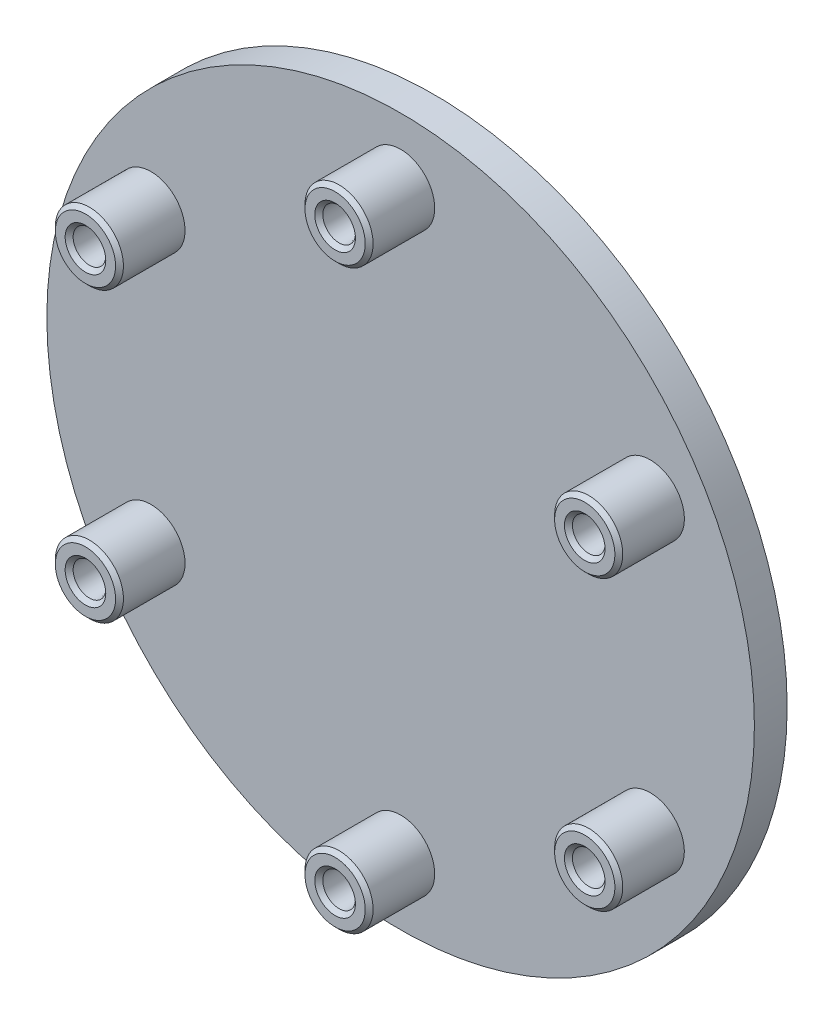
from build123d import *
from OCP.BRepFilletAPI import BRepFilletAPI_MakeChamfer

# Parameters (mm, degrees)
SKETCH1_R                     = 34.29
BOSS_EXTRUDE1_DEPTH           = 3.175
SKETCH2_R                     = 3.302
BOSS_EXTRUDE2_DEPTH           = 6.35
SKETCH3_R                     = 1.5875
CUT_EXTRUDE1_DEPTH            = 4.572
CUT_EXTRUDE1_DRAFT            = -1
CHAMFER1_SIZE                 = 0.381
CHAMFER1_SIZE2                = 0.387827593
CIRPATTERN1_COUNT             = 6
CIRPATTERN1_COPY_1_SKETCH_R   = 1.5875
CIRPATTERN1_COPY_1_DEPTH      = 4.572
CIRPATTERN1_COPY_1_DRAFT      = -1
CIRPATTERN1_COPY_2_SKETCH_R   = 1.5875
CIRPATTERN1_COPY_2_DEPTH      = 4.572
CIRPATTERN1_COPY_2_DRAFT      = -1
CIRPATTERN1_COPY_3_SKETCH_R   = 1.5875
CIRPATTERN1_COPY_3_DEPTH      = 4.572
CIRPATTERN1_COPY_3_DRAFT      = -1
CIRPATTERN1_COPY_4_SKETCH_R   = 1.5875
CIRPATTERN1_COPY_4_DEPTH      = 4.572
CIRPATTERN1_COPY_4_DRAFT      = -1
CIRPATTERN1_COPY_5_SKETCH_R   = 1.5875
CIRPATTERN1_COPY_5_DEPTH      = 4.572
CIRPATTERN1_COPY_5_DRAFT      = -1
CHAMFER1_OF_CIRPATTERN1_SIZE  = 0.381
CHAMFER1_OF_CIRPATTERN1_SIZE2 = 0.387827593


with BuildPart() as part:
    # Sketch1 → Boss-Extrude1 (new body)
    with BuildSketch(Plane.XY):
        Circle(SKETCH1_R)
    extrude(amount=BOSS_EXTRUDE1_DEPTH)

    # Sketch2 → Boss-Extrude2 (add)
    with BuildSketch(Plane.XY.offset(3.175)):
        with Locations((0, 27.94)):
            Circle(SKETCH2_R)
    boss_extrude2 = extrude(amount=BOSS_EXTRUDE2_DEPTH)


with BuildPart() as cut_extrude1_tool:
    # Sketch3 → Cut-Extrude1 (with draft: the straight prism first)
    with BuildSketch(Plane.XY.offset(9.525)):
        with Locations((0, 27.94)):
            Circle(SKETCH3_R)
    extrude(amount=-CUT_EXTRUDE1_DEPTH)
    # Cut-Extrude1: the draft: its side faces are tilted about the plane it starts from
    cut_extrude1_sides = [cut_extrude1_tool.faces().sort_by_distance(p)[0] for p in [
        (-1.5875, 27.94, 7.239),
    ]]
    draft(cut_extrude1_sides, Plane.XY.offset(9.525), CUT_EXTRUDE1_DRAFT)


with BuildPart() as part_1:
    add(part.part)

    # Cut-Extrude1: cut by cut_extrude1_tool
    add(cut_extrude1_tool.part, mode=Mode.SUBTRACT)

    # Chamfer1: one chamfer whose edges measure the first distance from different faces: ONE call of the kernel's chamfer builder (chamfer() names one face for all edges)
    chamfer1_edges_1 = [part_1.edges().sort_by_distance(p)[0] for p in [
        (-1.5875, 27.94, 9.525),
    ]]
    chamfer1_side_1 = [part_1.faces().sort_by_distance(p)[0] for p in [
        (-3.208605336, 27.94, 9.525),
    ]]
    chamfer1_edges_2 = [part_1.edges().sort_by_distance(p)[0] for p in [
        (-3.302, 27.94, 9.525),
    ]]
    chamfer1 = BRepFilletAPI_MakeChamfer(part_1.part.solid().wrapped)
    for e in chamfer1_edges_1:
        chamfer1.Add(CHAMFER1_SIZE, CHAMFER1_SIZE2, e.wrapped, chamfer1_side_1[0].wrapped)  # the first distance lies on this face
    for e in chamfer1_edges_2:
        chamfer1.Add(CHAMFER1_SIZE, e.wrapped)
    add(Compound.cast(chamfer1.Shape()), mode=Mode.REPLACE)

    # CirPattern1: Boss-Extrude2 ×6 about axis
    cirpattern1_axis = Axis((0, 0, -0.15875), (0, 0, 1))
    for i in range(1, CIRPATTERN1_COUNT):
        add(boss_extrude2.rotate(cirpattern1_axis, i * 360 / CIRPATTERN1_COUNT))


with BuildPart() as cirpattern1_copy_1_tool:
    # CirPattern1 copy 1 sketch → CirPattern1 copy 1 (with draft: the straight prism first)
    with BuildSketch(Plane(origin=(0, 0, 9.525), x_dir=(0.5000000000000001, 0.8660254037844386, 0), z_dir=(0, 0, 1))):
        with Locations((0, 27.94)):
            Circle(CIRPATTERN1_COPY_1_SKETCH_R)
    extrude(amount=-CIRPATTERN1_COPY_1_DEPTH)
    # CirPattern1 copy 1: the draft: its side faces are tilted about the plane it starts from
    cirpattern1_copy_1_sides = [cirpattern1_copy_1_tool.faces().sort_by_distance(p)[0] for p in [
        (-24.990499782, 12.595184671, 7.239),
    ]]
    draft(cirpattern1_copy_1_sides, Plane(origin=(0, 0, 9.525), x_dir=(0.5000000000000001, 0.8660254037844386, 0), z_dir=(0, 0, 1)), CIRPATTERN1_COPY_1_DRAFT)


with BuildPart() as part_2:
    add(part_1.part)

    # CirPattern1 copy 1: cut by cirpattern1_copy_1_tool
    add(cirpattern1_copy_1_tool.part, mode=Mode.SUBTRACT)


with BuildPart() as cirpattern1_copy_2_tool:
    # CirPattern1 copy 2 sketch → CirPattern1 copy 2 (with draft: the straight prism first)
    with BuildSketch(Plane(origin=(0, 0, 9.525), x_dir=(-0.4999999999999998, 0.8660254037844387, 0), z_dir=(0, 0, 1))):
        with Locations((0, 27.94)):
            Circle(CIRPATTERN1_COPY_2_SKETCH_R)
    extrude(amount=-CIRPATTERN1_COPY_2_DEPTH)
    # CirPattern1 copy 2: the draft: its side faces are tilted about the plane it starts from
    cirpattern1_copy_2_sides = [cirpattern1_copy_2_tool.faces().sort_by_distance(p)[0] for p in [
        (-23.402999782, -15.344815329, 7.239),
    ]]
    draft(cirpattern1_copy_2_sides, Plane(origin=(0, 0, 9.525), x_dir=(-0.4999999999999998, 0.8660254037844387, 0), z_dir=(0, 0, 1)), CIRPATTERN1_COPY_2_DRAFT)


with BuildPart() as part_3:
    add(part_2.part)

    # CirPattern1 copy 2: cut by cirpattern1_copy_2_tool
    add(cirpattern1_copy_2_tool.part, mode=Mode.SUBTRACT)


with BuildPart() as cirpattern1_copy_3_tool:
    # CirPattern1 copy 3 sketch → CirPattern1 copy 3 (with draft: the straight prism first)
    with BuildSketch(Plane(origin=(0, 0, 9.525), x_dir=(-1, 0, 0), z_dir=(0, 0, 1))):
        with Locations((0, 27.94)):
            Circle(CIRPATTERN1_COPY_3_SKETCH_R)
    extrude(amount=-CIRPATTERN1_COPY_3_DEPTH)
    # CirPattern1 copy 3: the draft: its side faces are tilted about the plane it starts from
    cirpattern1_copy_3_sides = [cirpattern1_copy_3_tool.faces().sort_by_distance(p)[0] for p in [
        (1.5875, -27.94, 7.239),
    ]]
    draft(cirpattern1_copy_3_sides, Plane(origin=(0, 0, 9.525), x_dir=(-1, 0, 0), z_dir=(0, 0, 1)), CIRPATTERN1_COPY_3_DRAFT)


with BuildPart() as part_4:
    add(part_3.part)

    # CirPattern1 copy 3: cut by cirpattern1_copy_3_tool
    add(cirpattern1_copy_3_tool.part, mode=Mode.SUBTRACT)


with BuildPart() as cirpattern1_copy_4_tool:
    # CirPattern1 copy 4 sketch → CirPattern1 copy 4 (with draft: the straight prism first)
    with BuildSketch(Plane(origin=(0, 0, 9.525), x_dir=(-0.5000000000000004, -0.8660254037844384, 0), z_dir=(0, 0, 1))):
        with Locations((0, 27.94)):
            Circle(CIRPATTERN1_COPY_4_SKETCH_R)
    extrude(amount=-CIRPATTERN1_COPY_4_DEPTH)
    # CirPattern1 copy 4: the draft: its side faces are tilted about the plane it starts from
    cirpattern1_copy_4_sides = [cirpattern1_copy_4_tool.faces().sort_by_distance(p)[0] for p in [
        (24.990499782, -12.595184671, 7.239),
    ]]
    draft(cirpattern1_copy_4_sides, Plane(origin=(0, 0, 9.525), x_dir=(-0.5000000000000004, -0.8660254037844384, 0), z_dir=(0, 0, 1)), CIRPATTERN1_COPY_4_DRAFT)


with BuildPart() as part_5:
    add(part_4.part)

    # CirPattern1 copy 4: cut by cirpattern1_copy_4_tool
    add(cirpattern1_copy_4_tool.part, mode=Mode.SUBTRACT)


with BuildPart() as cirpattern1_copy_5_tool:
    # CirPattern1 copy 5 sketch → CirPattern1 copy 5 (with draft: the straight prism first)
    with BuildSketch(Plane(origin=(0, 0, 9.525), x_dir=(0.5000000000000001, -0.8660254037844386, 0), z_dir=(0, 0, 1))):
        with Locations((0, 27.94)):
            Circle(CIRPATTERN1_COPY_5_SKETCH_R)
    extrude(amount=-CIRPATTERN1_COPY_5_DEPTH)
    # CirPattern1 copy 5: the draft: its side faces are tilted about the plane it starts from
    cirpattern1_copy_5_sides = [cirpattern1_copy_5_tool.faces().sort_by_distance(p)[0] for p in [
        (23.402999782, 15.344815329, 7.239),
    ]]
    draft(cirpattern1_copy_5_sides, Plane(origin=(0, 0, 9.525), x_dir=(0.5000000000000001, -0.8660254037844386, 0), z_dir=(0, 0, 1)), CIRPATTERN1_COPY_5_DRAFT)


with BuildPart() as part_6:
    add(part_5.part)

    # CirPattern1 copy 5: cut by cirpattern1_copy_5_tool
    add(cirpattern1_copy_5_tool.part, mode=Mode.SUBTRACT)

    # Chamfer1 of CirPattern1: one chamfer whose edges measure the first distance from different faces: ONE call of the kernel's chamfer builder (chamfer() names one face for all edges)
    chamfer1_of_cirpattern1_edges_1 = [part_6.edges().sort_by_distance(p)[0] for p in [
        (-24.990499782, 12.595184671, 9.525),
    ]]
    chamfer1_of_cirpattern1_side_1 = [part_6.faces().sort_by_distance(p)[0] for p in [
        (-25.80105245, 11.191266268, 9.525),
    ]]
    chamfer1_of_cirpattern1_edges_2 = [part_6.edges().sort_by_distance(p)[0] for p in [
        (-25.847749782, 11.110384117, 9.525),
    ]]
    chamfer1_of_cirpattern1_edges_3 = [part_6.edges().sort_by_distance(p)[0] for p in [
        (-23.402999782, -15.344815329, 9.525),
    ]]
    chamfer1_of_cirpattern1_side_3 = [part_6.faces().sort_by_distance(p)[0] for p in [
        (-22.592447114, -16.748733732, 9.525),
    ]]
    chamfer1_of_cirpattern1_edges_4 = [part_6.edges().sort_by_distance(p)[0] for p in [
        (-22.545749782, -16.829615883, 9.525),
    ]]
    chamfer1_of_cirpattern1_edges_5 = [part_6.edges().sort_by_distance(p)[0] for p in [
        (1.5875, -27.94, 9.525),
    ]]
    chamfer1_of_cirpattern1_side_5 = [part_6.faces().sort_by_distance(p)[0] for p in [
        (3.208605336, -27.94, 9.525),
    ]]
    chamfer1_of_cirpattern1_edges_6 = [part_6.edges().sort_by_distance(p)[0] for p in [
        (3.302, -27.94, 9.525),
    ]]
    chamfer1_of_cirpattern1_edges_7 = [part_6.edges().sort_by_distance(p)[0] for p in [
        (24.990499782, -12.595184671, 9.525),
    ]]
    chamfer1_of_cirpattern1_side_7 = [part_6.faces().sort_by_distance(p)[0] for p in [
        (25.80105245, -11.191266268, 9.525),
    ]]
    chamfer1_of_cirpattern1_edges_8 = [part_6.edges().sort_by_distance(p)[0] for p in [
        (25.847749782, -11.110384117, 9.525),
    ]]
    chamfer1_of_cirpattern1_edges_9 = [part_6.edges().sort_by_distance(p)[0] for p in [
        (23.402999782, 15.344815329, 9.525),
    ]]
    chamfer1_of_cirpattern1_side_9 = [part_6.faces().sort_by_distance(p)[0] for p in [
        (22.592447114, 16.748733732, 9.525),
    ]]
    chamfer1_of_cirpattern1_edges_10 = [part_6.edges().sort_by_distance(p)[0] for p in [
        (22.545749782, 16.829615883, 9.525),
    ]]
    chamfer1_of_cirpattern1 = BRepFilletAPI_MakeChamfer(part_6.part.solid().wrapped)
    for e in chamfer1_of_cirpattern1_edges_1:
        chamfer1_of_cirpattern1.Add(CHAMFER1_OF_CIRPATTERN1_SIZE, CHAMFER1_OF_CIRPATTERN1_SIZE2, e.wrapped, chamfer1_of_cirpattern1_side_1[0].wrapped)  # the first distance lies on this face
    for e in chamfer1_of_cirpattern1_edges_2:
        chamfer1_of_cirpattern1.Add(CHAMFER1_OF_CIRPATTERN1_SIZE, e.wrapped)
    for e in chamfer1_of_cirpattern1_edges_3:
        chamfer1_of_cirpattern1.Add(CHAMFER1_OF_CIRPATTERN1_SIZE, CHAMFER1_OF_CIRPATTERN1_SIZE2, e.wrapped, chamfer1_of_cirpattern1_side_3[0].wrapped)  # the first distance lies on this face
    for e in chamfer1_of_cirpattern1_edges_4:
        chamfer1_of_cirpattern1.Add(CHAMFER1_OF_CIRPATTERN1_SIZE, e.wrapped)
    for e in chamfer1_of_cirpattern1_edges_5:
        chamfer1_of_cirpattern1.Add(CHAMFER1_OF_CIRPATTERN1_SIZE, CHAMFER1_OF_CIRPATTERN1_SIZE2, e.wrapped, chamfer1_of_cirpattern1_side_5[0].wrapped)  # the first distance lies on this face
    for e in chamfer1_of_cirpattern1_edges_6:
        chamfer1_of_cirpattern1.Add(CHAMFER1_OF_CIRPATTERN1_SIZE, e.wrapped)
    for e in chamfer1_of_cirpattern1_edges_7:
        chamfer1_of_cirpattern1.Add(CHAMFER1_OF_CIRPATTERN1_SIZE, CHAMFER1_OF_CIRPATTERN1_SIZE2, e.wrapped, chamfer1_of_cirpattern1_side_7[0].wrapped)  # the first distance lies on this face
    for e in chamfer1_of_cirpattern1_edges_8:
        chamfer1_of_cirpattern1.Add(CHAMFER1_OF_CIRPATTERN1_SIZE, e.wrapped)
    for e in chamfer1_of_cirpattern1_edges_9:
        chamfer1_of_cirpattern1.Add(CHAMFER1_OF_CIRPATTERN1_SIZE, CHAMFER1_OF_CIRPATTERN1_SIZE2, e.wrapped, chamfer1_of_cirpattern1_side_9[0].wrapped)  # the first distance lies on this face
    for e in chamfer1_of_cirpattern1_edges_10:
        chamfer1_of_cirpattern1.Add(CHAMFER1_OF_CIRPATTERN1_SIZE, e.wrapped)
    add(Compound.cast(chamfer1_of_cirpattern1.Shape()), mode=Mode.REPLACE)


solid = part_6.part
